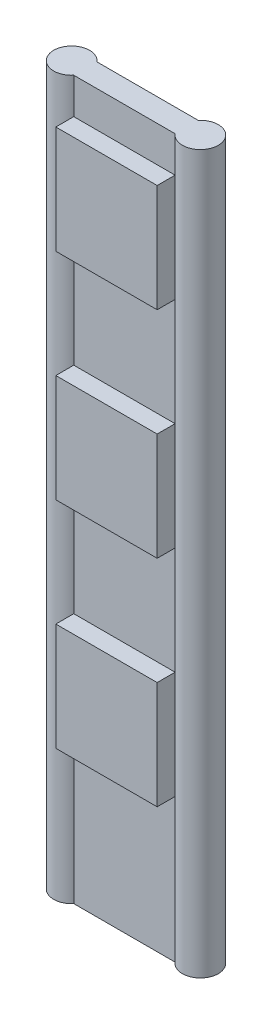
from build123d import *

# Parameters (mm, degrees)
EXTRUDE_1_DEPTH = 2000
SKETCH_3_W      = 282.482591868
SKETCH_3_H      = 300
EXTRUDE_2_DEPTH = 50


with BuildPart() as part:
    # 草圖2 → 填料-伸長1 (new body)
    with BuildSketch(Plane(origin=(0, 0, 0), x_dir=(1, 0, 0), z_dir=(0, 1, 0))):
        with BuildLine():
            Line((-141.241295934, 21.394189404), (141.241295934, 21.394189404))
            ThreePointArc((141.241295934, 21.394189404), (229.43942383, -10.868839364), (141.241295934, -43.131868132))
            Line((141.241295934, -43.131868132), (-141.241295934, -43.131868132))
            ThreePointArc((-141.241295934, -43.131868132), (-229.43942383, -10.868839364), (-141.241295934, 21.394189404))
        make_face()
    extrude(amount=EXTRUDE_1_DEPTH)

    # 草圖3 → 填料-伸長2 (add)
    with BuildSketch(Plane.XY.offset(43.131868132)):
        with Locations((0, 550)):
            Rectangle(SKETCH_3_W, SKETCH_3_H)
        with Locations((0, 1150)):
            Rectangle(SKETCH_3_W, SKETCH_3_H)
        with Locations((0, 1750)):
            Rectangle(SKETCH_3_W, SKETCH_3_H)
    extrude(amount=EXTRUDE_2_DEPTH)


solid = part.part
